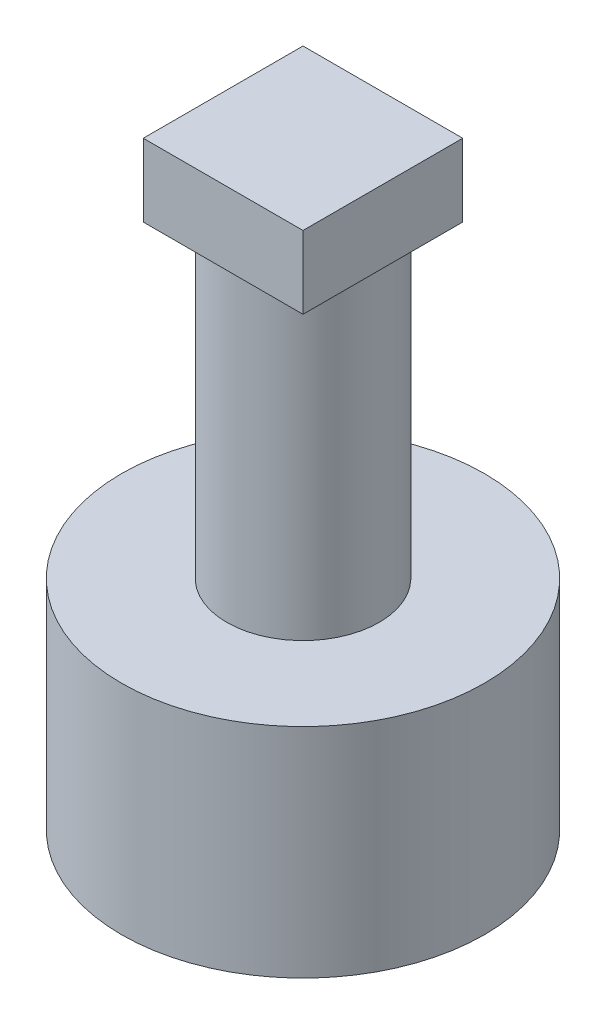
from build123d import *

# Parameters (mm, degrees)
SKETCH1_R           = 5
SKETCH1_W           = 6.6
SKETCH1_H           = 5.1
BOSS_EXTRUDE1_DEPTH = 5
SKETCH2_R           = 5
BOSS_EXTRUDE2_DEPTH = 1
SKETCH3_R           = 2.1
BOSS_EXTRUDE3_DEPTH = 8.5
SKETCH4_W           = 4.4
SKETCH4_H           = 4.4
BOSS_EXTRUDE4_DEPTH = 2


with BuildPart() as part:
    # Sketch1 → Boss-Extrude1 (new body)
    with BuildSketch(Plane(origin=(0, 0, 0), x_dir=(1, 0, 0), z_dir=(0, 1, 0))):
        Circle(SKETCH1_R)
        Rectangle(SKETCH1_W, SKETCH1_H, mode=Mode.SUBTRACT)
    extrude(amount=BOSS_EXTRUDE1_DEPTH)

    # Sketch2 → Boss-Extrude2 (add)
    with BuildSketch(Plane(origin=(0, 5, 0), x_dir=(1, 0, 0), z_dir=(0, 1, 0))):
        Circle(SKETCH2_R)
    extrude(amount=BOSS_EXTRUDE2_DEPTH)

    # Sketch3 → Boss-Extrude3 (add)
    with BuildSketch(Plane(origin=(0, 6, 0), x_dir=(1, 0, 0), z_dir=(0, 1, 0))):
        Circle(SKETCH3_R)
    extrude(amount=BOSS_EXTRUDE3_DEPTH)

    # Sketch4 → Boss-Extrude4 (add)
    with BuildSketch(Plane(origin=(0, 14.5, 0), x_dir=(1, 0, 0), z_dir=(0, 1, 0))):
        Rectangle(SKETCH4_W, SKETCH4_H)
    extrude(amount=BOSS_EXTRUDE4_DEPTH)


solid = part.part
